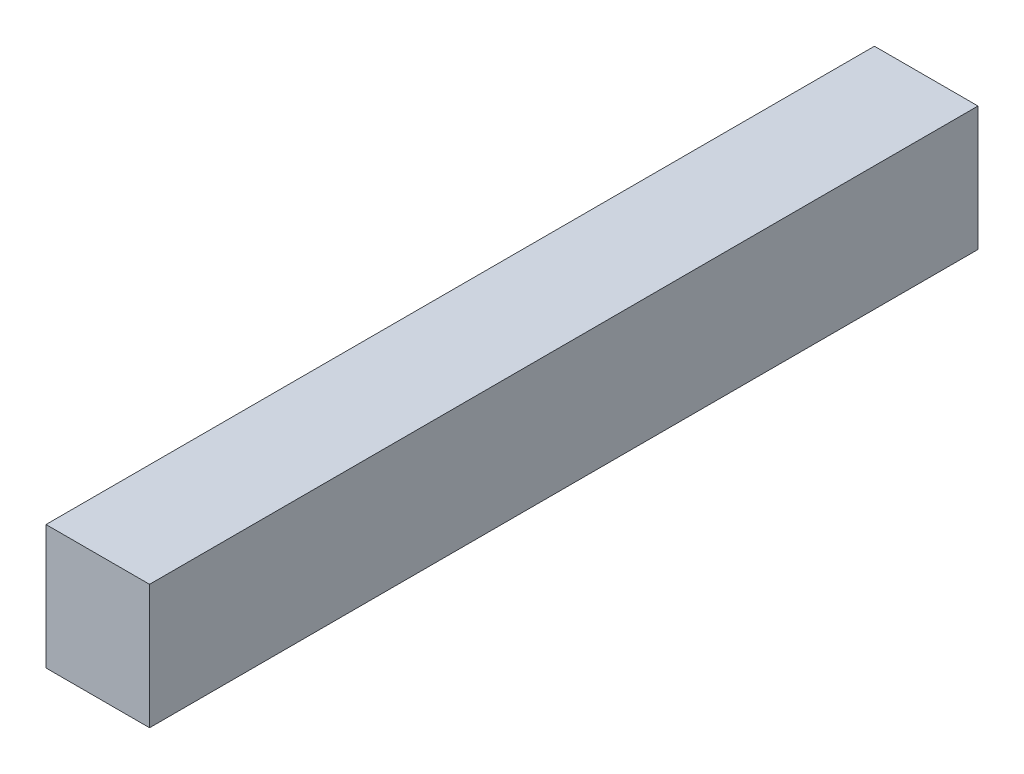
from build123d import *

# Parameters (mm, degrees)
BOSS_EXTRUDE1_DEPTH      = 100
BOSS_EXTRUDE1_DEPTH_BACK = 100
SKETCH1_W                = 25
SKETCH1_H                = 30


with BuildPart() as part:
    # Sketch1 → Boss-Extrude1 (new, two sides: drawn at the far end of the back side and taken through both)
    with BuildSketch(Plane.XY.offset(-BOSS_EXTRUDE1_DEPTH_BACK)):
        Rectangle(SKETCH1_W, SKETCH1_H)
    extrude(amount=BOSS_EXTRUDE1_DEPTH + BOSS_EXTRUDE1_DEPTH_BACK)


solid = part.part
